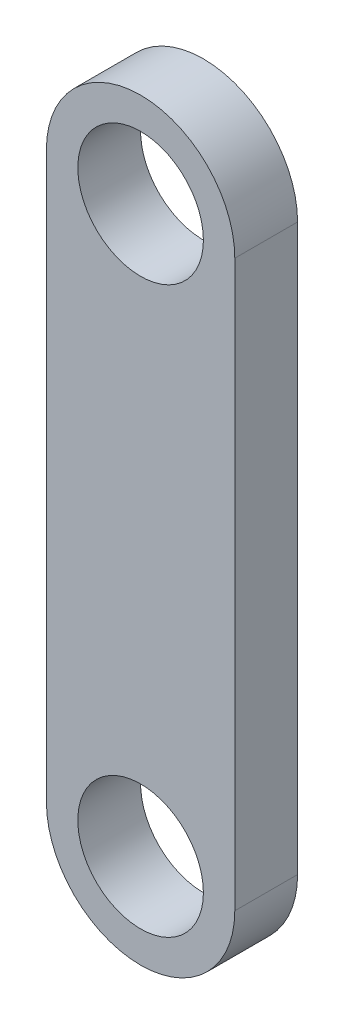
from build123d import *

# Parameters (mm, degrees)
SKETCH1_R           = 5
BOSS_EXTRUDE1_DEPTH = 2.5
SCALE1_SCALE        = 0.3


with BuildPart() as part:
    # Sketch1 → Boss-Extrude1 (new body, symmetric)
    with BuildSketch(Plane.XY):
        with BuildLine():
            Line((72.497051665, 56.504761557), (72.497051665, 11.504761557))
            ThreePointArc((72.497051665, 11.504761557), (64.997051665, 4.004761557), (57.497051665, 11.504761557))
            Line((57.497051665, 11.504761557), (57.497051665, 56.504761557))
            ThreePointArc((57.497051665, 56.504761557), (64.997051665, 64.004761557), (72.497051665, 56.504761557))
        make_face()
        with Locations((64.997051665, 56.504761557)):
            Circle(SKETCH1_R, mode=Mode.SUBTRACT)
        with Locations((64.997051665, 11.504761557)):
            Circle(SKETCH1_R, mode=Mode.SUBTRACT)
    extrude(amount=BOSS_EXTRUDE1_DEPTH, both=True)


with BuildPart() as part_1:
    # Scale1: scaled about (64.997051665, 34.004761557, 0)
    add(part.part.scale(SCALE1_SCALE).moved(Location((45.497936166, 23.80333309, 0))))


solid = part_1.part
